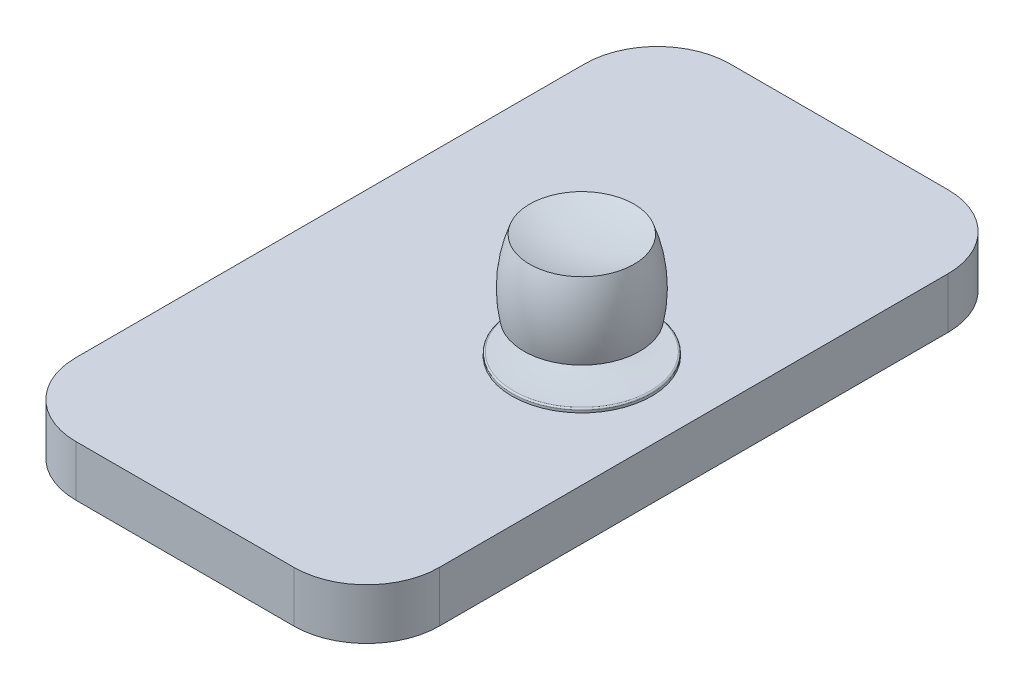
from build123d import *

# Parameters (mm, degrees)
SKETCH1_W           = 127
SKETCH1_H           = 228.6
BOSS_EXTRUDE1_DEPTH = 17.78
FILLET1_R           = 25.4


with BuildPart() as part:
    # Sketch1 → Boss-Extrude1 (new body)
    with BuildSketch(Plane(origin=(0, 0, 0), x_dir=(1, 0, 0), z_dir=(0, 1, 0))):
        Rectangle(SKETCH1_W, SKETCH1_H)
    extrude(amount=BOSS_EXTRUDE1_DEPTH)

    # Fillet1
    fillet1_edges = [part.edges().sort_by_distance(p)[0] for p in [
        (63.5, 8.89, 114.3),
        (-63.5, 8.89, 114.3),
        (-63.5, 8.89, -114.3),
        (63.5, 8.89, -114.3),
    ]]
    fillet(fillet1_edges, radius=FILLET1_R)

    # Sketch3 → Revolve1 (revolve)
    with BuildSketch(Plane.XY):
        with BuildLine():
            Line((24.400711068, 17.78), (0, 17.78))
            Line((0, 17.78), (0, 18.621092674))
            ThreePointArc((0, 18.621092674), (0.153192874, 18.984652715), (0.520377573, 19.12894186))
            ThreePointArc((0.520377573, 19.12894186), (9.452590015, 19.351960716), (18.319397174, 20.453726269))
            Line((18.319397174, 20.453726269), (18.319397174, 23.831447825))
            Line((18.319397174, 23.831447825), (18.319397174, 27.940464373))
            Line((18.319397174, 27.940464373), (24.400711068, 27.940464373))
            Line((24.400711068, 27.940464373), (24.400711068, 23.831447825))
            Line((24.400711068, 23.831447825), (24.400711068, 21.732479509))
            Line((24.400711068, 21.732479509), (24.400711068, 17.78))
        make_face()
    revolve(axis=Axis((24.400711068, 21.732479509, 0), (0, -1, 0)))

    # Sketch4 → Revolve2 (revolve)
    with BuildSketch(Plane.XY):
        with BuildLine():
            Line((24.400711068, 27.940464373), (24.400711068, 52.102517499))
            ThreePointArc((24.400711068, 52.102517499), (33.609505059, 52.688947823), (42.630480882, 54.630025491))
            ThreePointArc((42.630480882, 54.630025491), (45.38750409, 42.105790986), (44.646315408, 29.303124613))
            ThreePointArc((44.646315408, 29.303124613), (34.587150849, 27.67630429), (24.400711068, 27.940464373))
        make_face()
    revolve(axis=Axis((24.400711068, 27.940464373, 0), (0, 1, 0)))


solid = part.part
